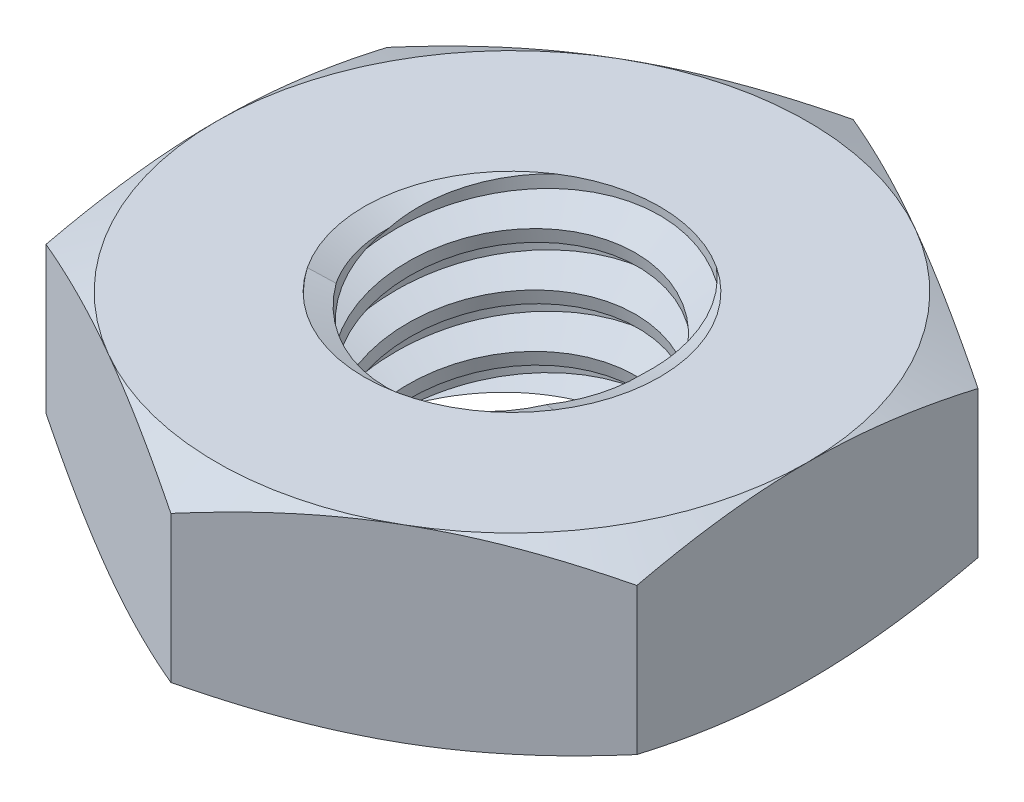
from build123d import *

# Parameters (mm, degrees)
EXTRUDE1_DEPTH      = 0.8
SKETCH2_W           = 1.25
SKETCH2_H           = 1.6
LPATTERN1_COUNT     = 4
LPATTERN1_PITCH     = 0.45
LPATTERN1_COL_COUNT = 2
LPATTERN1_COL_PITCH = 0.45


with BuildPart() as part:
    # Sketch1 → Extrude1 (new body, symmetric)
    with BuildSketch(Plane(origin=(0, 0, 0), x_dir=(1, 0, 0), z_dir=(0, 1, 0))):
        Polygon((0, 2.886751346), (-2.5, 1.443375673), (-2.5, -1.443375673), (0, -2.886751346), (2.5, -1.443375673), (2.5, 1.443375673), align=None)
    extrude(amount=EXTRUDE1_DEPTH, both=True)

    # Sketch4 → Cut-Revolve2 (revolve, cut)
    with BuildSketch(Plane(origin=(0, 0, 0), x_dir=(0, 0, -1), z_dir=(1, 0, 0))):
        Polygon((0, 0.8), (1.25, 0.8), (1.045159814, 0.704481453), (1.045159814, -0.704481453), (1.25, -0.8), (0, -0.8), align=None)
    revolve(axis=Axis((0, 0.8, 0), (0, 1, 0)), mode=Mode.SUBTRACT)


with BuildPart() as body_2:
    # Sketch2 → Revolve1 (revolve)
    with BuildSketch(Plane(origin=(0, 0, 0), x_dir=(0, 0, -1), z_dir=(1, 0, 0))):
        with Locations((0.625, 0)):
            Rectangle(SKETCH2_W, SKETCH2_H)
    revolve(axis=Axis((0, -2.05, 0), (0, 1, 0)))

    # Sketch3 → Cut-Revolve1 (revolve, cut)
    with BuildSketch(Plane(origin=(0, 0, 0), x_dir=(0, 0, -1), z_dir=(1, 0, 0))):
        Polygon((1.259964856, 0.744639688), (1.329718849, 0.357117504), (1.065089526, 0.452369191), (1.045159814, 0.563089815), align=None)
    cut_revolve1 = revolve(axis=Axis((0, 0.8, 0.086794729), (0, -0.984183324, -0.177152998)), mode=Mode.SUBTRACT)

    # LPattern1: Cut-Revolve1 ×4
    with Locations(*[(0, -i * LPATTERN1_PITCH, 0) for i in range(1, LPATTERN1_COUNT)]):
        add(cut_revolve1, mode=Mode.SUBTRACT)

    # LPattern1 col: Cut-Revolve1 ×2
    with Locations(*[(0, i * LPATTERN1_COL_PITCH, 0) for i in range(1, LPATTERN1_COL_COUNT)]):
        add(cut_revolve1, mode=Mode.SUBTRACT)


with BuildPart() as part_1:
    add(part.part)

    # Combine1: cut body 2
    add(body_2.part, mode=Mode.SUBTRACT)

    # Sketch5 → Cut-Revolve3 (revolve, cut)
    with BuildSketch(Plane(origin=(0, 0, 0), x_dir=(0, 0, -1), z_dir=(1, 0, 0))):
        Polygon((0, -0.8), (2.5, -0.8), (2.886751346, -0.619654886), (2.886751346, 0.619654886), (2.5, 0.8), (0, 0.8), (0, 2.07), (4.156751346, 2.07), (4.156751346, -2.07), (0, -2.07), align=None)
    revolve(axis=Axis((0, -0.8, 0), (0, 1, 0)), mode=Mode.SUBTRACT)


solid = part_1.part
